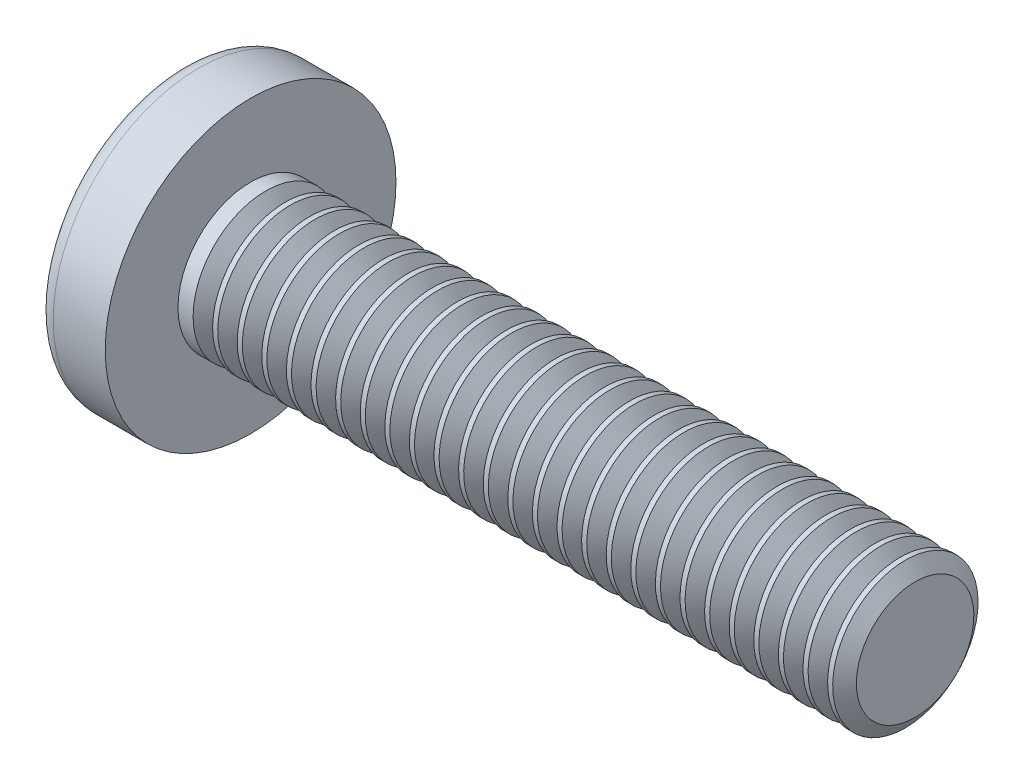
from build123d import *

# Parameters (mm, degrees)
SKETCH3_W         = 0.87
SKETCH3_H         = 3.92
SKETCH4_W         = 0.435
SKETCH4_H         = 0.435
CIRPATTERN1_COUNT = 2
CIRPATTERN1_ANGLE = 90
THDSCHPAT_COUNT   = 27
THDSCHPAT_PITCH   = 0.592307692


with BuildPart() as part:
    # BodySke → Base-Revolve (revolve)
    with BuildSketch(Plane.XY):
        with BuildLine():
            Line((2.6, 1.75), (2.6, 3.5))
            Line((2.6, 3.5), (1.34704395, 3.5))
            ThreePointArc((1.34704395, 3.5), (1.148257308, 3.449978203), (0.996821452, 3.311827957))
            ThreePointArc((0.996821452, 3.311827957), (0.254607442, 1.729295913), (0, 0))
            Line((0, 0), (18.6, 0))
            Line((18.6, 0), (18.6, 1.75))
            Line((18.6, 1.75), (2.6, 1.75))
        make_face()
    revolve(axis=Axis((-25.4, 0, 0), (1, 0, 0)))

    # Sketch3 → Cut-Loft1 section 0
    with BuildSketch(Plane(origin=(0, 0, 0), x_dir=(0, 0, -1), z_dir=(1, 0, 0))):
        Rectangle(SKETCH3_W, SKETCH3_H)
    # Sketch4 → Cut-Loft1 section 1
    with BuildSketch(Plane(origin=(1.95, 0, 0), x_dir=(0, 0, -1), z_dir=(1, 0, 0))):
        Rectangle(SKETCH4_W, SKETCH4_H)
    cut_loft1 = loft(mode=Mode.SUBTRACT)

    # CirPattern1: Cut-Loft1 ×2 about axis
    cirpattern1_axis = Axis((0, 0, 0), (1, 0, 0))
    for i in range(1, CIRPATTERN1_COUNT):
        add(cut_loft1.rotate(cirpattern1_axis, i * CIRPATTERN1_ANGLE / (CIRPATTERN1_COUNT - 1)), mode=Mode.SUBTRACT)

    # ThdSchSke → ThreadSchematic (revolve, cut)
    with BuildSketch(Plane.XY):
        Polygon((3.2, -1.4145), (2.965080371, -1.75), (2.965080371, -2.1875), (3.434919629, -2.1875), (3.434919629, -1.75), align=None)
    threadschematic = revolve(axis=Axis((-3.175, 0, 0), (1, 0, 0)), mode=Mode.SUBTRACT)

    # ThdSchPat: ThreadSchematic ×27
    with Locations(*[(i * THDSCHPAT_PITCH, 0, 0) for i in range(1, THDSCHPAT_COUNT)]):
        add(threadschematic, mode=Mode.SUBTRACT)


solid = part.part
